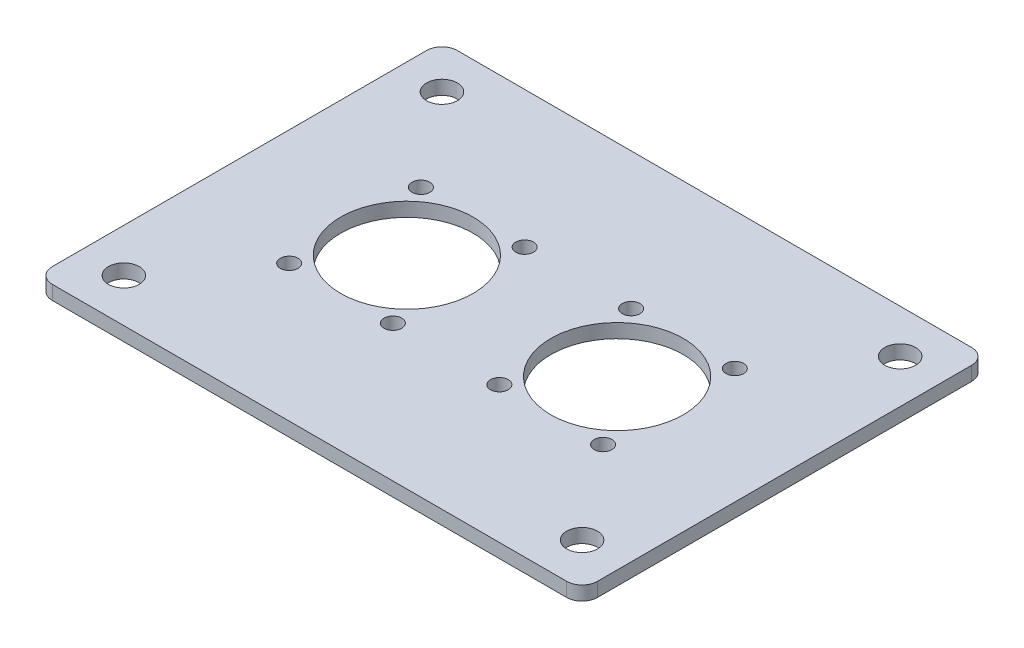
from build123d import *

# Parameters (mm, degrees)
SKETCH1_R           = 12.0015
SKETCH1_R_2         = 2.794
SKETCH1_R_3         = 1.6002
BOSS_EXTRUDE1_DEPTH = 2.54


with BuildPart() as part:
    # Sketch1 → Boss-Extrude1 (new body)
    with BuildSketch(Plane(origin=(0, 0, 0), x_dir=(1, 0, 0), z_dir=(0, 1, 0))):
        with BuildLine():
            Line((-46.609, -36.703), (46.609, -36.703))
            ThreePointArc((46.609, -36.703), (48.584656347, -35.884656347), (49.403, -33.909))
            Line((49.403, -33.909), (49.403, 33.909))
            ThreePointArc((49.403, 33.909), (48.584656347, 35.884656347), (46.609, 36.703))
            Line((46.609, 36.703), (-46.609, 36.703))
            ThreePointArc((-46.609, 36.703), (-48.584656347, 35.884656347), (-49.403, 33.909))
            Line((-49.403, 33.909), (-49.403, -33.909))
            ThreePointArc((-49.403, -33.909), (-48.584656347, -35.884656347), (-46.609, -36.703))
        make_face()
        with Locations((-19.05, 0)):
            Circle(SKETCH1_R, mode=Mode.SUBTRACT)
        with Locations((19.05, 0)):
            Circle(SKETCH1_R, mode=Mode.SUBTRACT)
        with Locations((-41.529, 28.829)):
            Circle(SKETCH1_R_2, mode=Mode.SUBTRACT)
        with Locations((-28.448, -11.938)):
            Circle(SKETCH1_R_3, mode=Mode.SUBTRACT)
        with Locations((-9.652, -11.938)):
            Circle(SKETCH1_R_3, mode=Mode.SUBTRACT)
        with Locations((-9.652, 11.938)):
            Circle(SKETCH1_R_3, mode=Mode.SUBTRACT)
        with Locations((-28.448, 11.938)):
            Circle(SKETCH1_R_3, mode=Mode.SUBTRACT)
        with Locations((9.652, 11.938)):
            Circle(SKETCH1_R_3, mode=Mode.SUBTRACT)
        with Locations((28.448, 11.938)):
            Circle(SKETCH1_R_3, mode=Mode.SUBTRACT)
        with Locations((28.448, -11.938)):
            Circle(SKETCH1_R_3, mode=Mode.SUBTRACT)
        with Locations((9.652, -11.938)):
            Circle(SKETCH1_R_3, mode=Mode.SUBTRACT)
        with Locations((41.529, 28.829)):
            Circle(SKETCH1_R_2, mode=Mode.SUBTRACT)
        with Locations((41.529, -28.829)):
            Circle(SKETCH1_R_2, mode=Mode.SUBTRACT)
        with Locations((-41.529, -28.829)):
            Circle(SKETCH1_R_2, mode=Mode.SUBTRACT)
    extrude(amount=BOSS_EXTRUDE1_DEPTH)


solid = part.part
